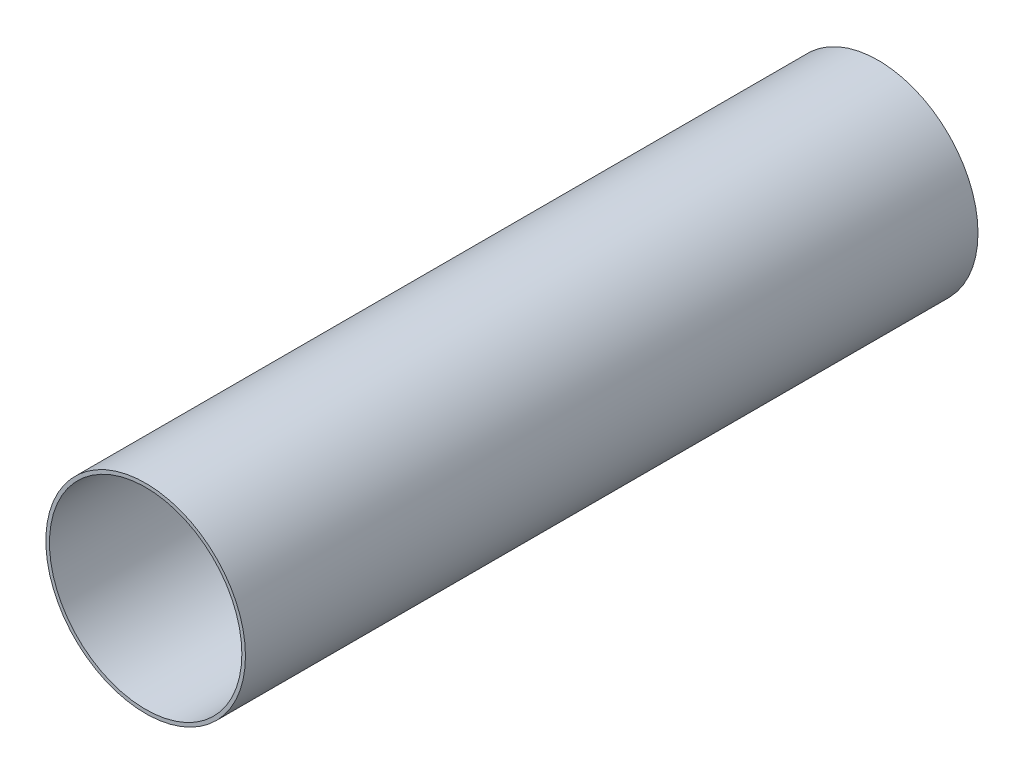
from build123d import *

# Parameters (mm, degrees)
SKETCH1_R           = 20.7645
SKETCH1_R_2         = 20.0145
EXTRUDE_THIN1_DEPTH = 152.4


with BuildPart() as part:
    # Sketch1 → Extrude-Thin1 (new body)
    with BuildSketch(Plane.XY):
        Circle(SKETCH1_R)
        Circle(SKETCH1_R_2, mode=Mode.SUBTRACT)
    extrude(amount=EXTRUDE_THIN1_DEPTH)


solid = part.part
